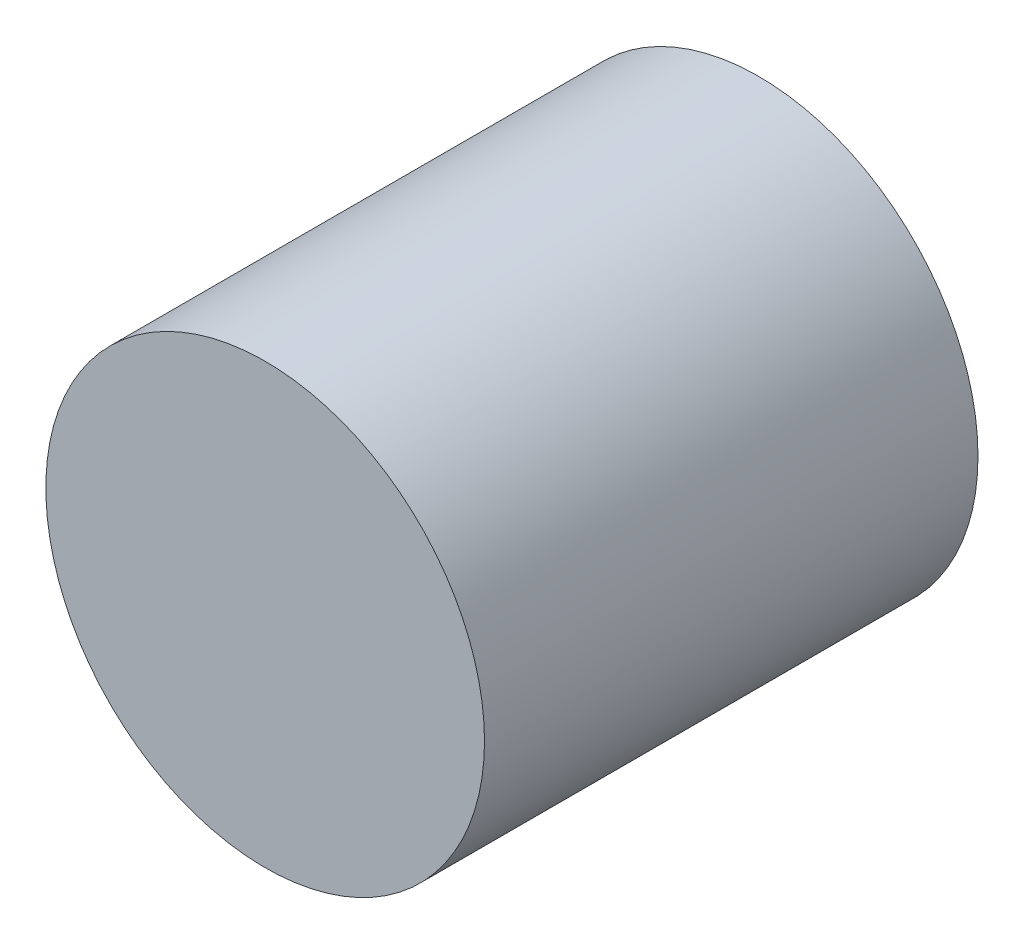
from build123d import *

# Parameters (mm, degrees)
SKETCH_1_R      = 4
EXTRUDE_1_DEPTH = 4.5


with BuildPart() as part:
    # 草圖1 → 填料-伸長1 (new body, symmetric)
    with BuildSketch(Plane.XY):
        Circle(SKETCH_1_R)
    extrude(amount=EXTRUDE_1_DEPTH, both=True)


solid = part.part
